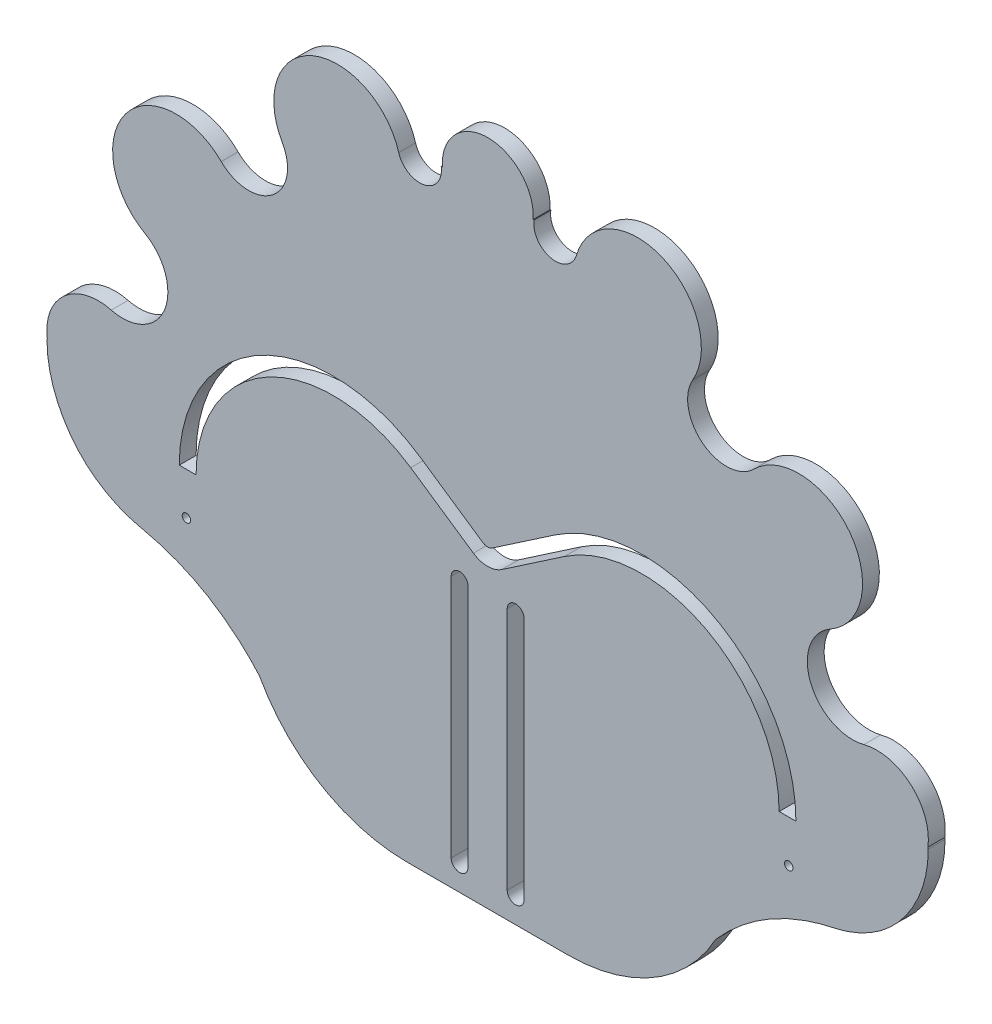
from build123d import *

# Parameters (mm, degrees)
BOSS_EXTRUDE3_DEPTH      = 3
BOSS_EXTRUDE4_DEPTH      = 3
CUT_EXTRUDE11_DEPTH      = 111.873556651
CUT_EXTRUDE11_DEPTH_BACK = 111.873556651
SKETCH6_W                = 30
SKETCH6_H                = 41
BOSS_EXTRUDE5_DEPTH      = 40
SKETCH7_W                = 88.745964224
SKETCH7_H                = 3
BOSS_EXTRUDE6_DEPTH      = 41
CUT_EXTRUDE12_DEPTH      = 118.830155579
CUT_EXTRUDE12_DEPTH_BACK = 118.830155579
BOSS_EXTRUDE7_DEPTH      = 3
CUT_EXTRUDE13_START      = 3
SKETCH11_W               = 10
SKETCH11_H               = 13.79344676
CUT_EXTRUDE13_DEPTH      = 41
SKETCH12_R               = 1.55
CUT_EXTRUDE14_DEPTH      = 118.830155613
CUT_EXTRUDE14_DEPTH_BACK = 118.830155613
SKETCH13_R               = 0.75
CUT_EXTRUDE15_DEPTH      = 118.830155613
CUT_EXTRUDE15_DEPTH_BACK = 118.830155613
CUT_EXTRUDE17_START      = 3
SKETCH14_W               = 30.416262865
SKETCH14_H               = 42.907687787
CUT_EXTRUDE17_DEPTH      = 41
SKETCH16_R               = 1.5
CUT_EXTRUDE19_DEPTH      = 111.873556651
CUT_EXTRUDE19_DEPTH_BACK = 111.873556651


with BuildPart() as part:
    # Sketch2 → Boss-Extrude3 (new body)
    with BuildSketch(Plane.XY):
        with BuildLine():
            ThreePointArc((47.50430531, 50.643316247), (38.392532309, 50.044854207), (36.609276159, 59.000442494))
            ThreePointArc((36.609276159, 59.000442494), (31.22500556, 75.135535905), (15.851175796, 67.857008055))
            ThreePointArc((15.851175796, 67.857008055), (11.292148271, 65.146162721), (8.27578906, 69.509073619))
            ThreePointArc((8.27578906, 69.509073619), (8.209835801, 69.516894322), (8.143875152, 69.524652444))
            ThreePointArc((8.143875152, 69.524652444), (0.040205316, 78.121761213), (-8.072309219, 69.532998094))
            ThreePointArc((-8.072309219, 69.532998094), (-8.174057892, 69.521110302), (-8.27578906, 69.509073619))
            ThreePointArc((-8.27578906, 69.509073619), (-11.292148299, 65.146162715), (-15.851175812, 67.857008111))
            ThreePointArc((-15.851175812, 67.857008111), (-31.225005545, 75.135535912), (-36.609276205, 59.000442573))
            ThreePointArc((-36.609276205, 59.000442573), (-38.39253227, 50.044854237), (-47.504305306, 50.643316242))
            ThreePointArc((-47.504305306, 50.643316242), (-64.562942613, 49.491387864), (-61.124617501, 32.743194941))
            ThreePointArc((-61.124617501, 32.743194941), (-57.616854175, 22.690844698), (-67.122680626, 17.895700022))
            ThreePointArc((-67.122680626, 17.895700022), (-67.381711192, 17.958536274), (-67.642453618, 18.013841027))
            ThreePointArc((-67.642453618, 18.013841027), (-78.427805312, 10.854202298), (-71.372982112, 0))
            Line((-71.372982112, 0), (71.372982112, 0))
            ThreePointArc((71.372982112, 0), (78.369977301, 11.114396723), (67.122680666, 17.895700032))
            ThreePointArc((67.122680666, 17.895700032), (57.616854183, 22.690844679), (61.124617501, 32.743194941))
            ThreePointArc((61.124617501, 32.743194941), (64.562942615, 49.491387862), (47.50430531, 50.643316247))
        make_face()
    extrude(amount=BOSS_EXTRUDE3_DEPTH)

    # Sketch4 → Boss-Extrude4 (add)
    with BuildSketch(Plane.XY):
        with BuildLine():
            Line((-44.372982112, 0), (-57.872982112, 0))
            Line((-57.872982112, 0), (-57.872982112, -13.5))
            ThreePointArc((-57.872982112, -13.5), (-50.941516146, -11.584678656), (-45.97686273, -6.382189564))
            ThreePointArc((-45.97686273, -6.382189564), (-45.287489461, -3.162806043), (-44.372982112, 0))
        make_face()
        with BuildLine():
            Line((-57.872982112, -13.5), (-57.872982112, 0))
            Line((-57.872982112, 0), (-71.372982112, 0))
            ThreePointArc((-71.372982112, 0), (-67.418923658, -9.545941546), (-57.872982112, -13.5))
        make_face()
        with BuildLine():
            Line((-57.872982112, -13.502334306), (-57.872982112, -13.5))
            ThreePointArc((-57.872982112, -13.5), (-67.418923658, -9.545941546), (-71.372982112, 0))
            ThreePointArc((-71.372982112, 0), (-72.451224877, 0.304022071), (-73.484512677, 0.73686523))
            ThreePointArc((-73.484512677, 0.73686523), (-74.477917841, 1.305497745), (-75.393009288, 1.993105481))
            ThreePointArc((-75.393009288, 1.993105481), (-76.19177077, 2.763005392), (-76.892036557, 3.623466668))
            ThreePointArc((-76.892036557, 3.623466668), (-77.482473018, 4.559883509), (-77.956141708, 5.560448192))
            ThreePointArc((-77.956141708, 5.560448192), (-78.314438673, 6.641735343), (-78.536342603, 7.759016536))
            Line((-78.536342603, 7.759016536), (-78.5829279, 7.5))
            add(Edge.make_bspline(
                [(-78.5829279, 7.5), (-78.619378381, 2.110973886), (-75.05397773, -6.403058313), (-65.775580858, -12.380201513), (-60.383408465, -13.5022688), (-57.872982112, -13.502334306)],
                knots=[0, 0, 0, 0, 0.497531388, 0.760341967, 0.99111058, 0.99111058, 0.99111058, 0.99111058], degree=3))
        make_face()
        with BuildLine():
            Line((57.872982112, 0), (44.372982112, 0))
            ThreePointArc((44.372982112, 0), (45.287489461, -3.162806043), (45.97686273, -6.382189564))
            ThreePointArc((45.97686273, -6.382189564), (50.899542414, -11.559461007), (57.775049798, -13.499644783))
            add(Edge.make_bspline(
                [(57.872982112, -13.498764325), (57.840342719, -13.499136412), (57.807698516, -13.49942994), (57.775049798, -13.499644783)],
                knots=[0.991262366, 0.991262366, 0.991262366, 0.991262366, 0.994213276, 0.994213276, 0.994213276, 0.994213276], degree=3))
            Line((57.872982112, -13.498764325), (57.872982112, 0))
        make_face()
        with BuildLine():
            Line((71.372982112, 0), (57.872982112, 0))
            Line((57.872982112, 0), (57.872982112, -13.498764325))
            add(Edge.make_bspline(
                [(58.880524263, -13.462349677), (58.545403195, -13.482744614), (58.209448198, -13.494928627), (57.872982112, -13.498764325)],
                knots=[0.960842647, 0.960842647, 0.960842647, 0.960842647, 0.991262366, 0.991262366, 0.991262366, 0.991262366], degree=3))
            ThreePointArc((58.880524263, -13.462349677), (67.768734207, -9.182814954), (71.372982112, 0))
        make_face()
        with BuildLine():
            ThreePointArc((73.484512677, 0.73686523), (72.451224877, 0.304022071), (71.372982112, 0))
            ThreePointArc((71.372982112, 0), (67.768734207, -9.182814954), (58.880524263, -13.462349677))
            add(Edge.make_bspline(
                [(78.5829279, 7.5), (78.674659632, 1.535679134), (73.703653617, -8.978697254), (63.479979045, -13.182434147), (58.880524263, -13.462349677)],
                knots=[0, 0, 0, 0, 0.543339428, 0.960842647, 0.960842647, 0.960842647, 0.960842647], degree=3))
            Line((78.5829279, 7.5), (78.536342603, 7.759016536))
            ThreePointArc((78.536342603, 7.759016536), (78.314438673, 6.641735343), (77.956141708, 5.560448192))
            ThreePointArc((77.956141708, 5.560448192), (77.482473018, 4.559883509), (76.892036557, 3.623466668))
            ThreePointArc((76.892036557, 3.623466668), (76.19177077, 2.763005392), (75.393009288, 1.993105481))
            ThreePointArc((75.393009288, 1.993105481), (74.477917841, 1.305497745), (73.484512677, 0.73686523))
        make_face()
    extrude(amount=BOSS_EXTRUDE4_DEPTH)

    # Sketch5 → Cut-Extrude11 (cut, two sides)
    with BuildSketch(Plane.XY) as cut_extrude11_sk:
        with BuildLine():
            ThreePointArc((-12.027368937, 22.734284418), (-40.359872584, 24.307893309), (-55, 0))
            Line((-55, 0), (-52, 0))
            ThreePointArc((-52, 0), (-38.956977393, 21.65612313), (-13.715292326, 20.254180663))
            Line((-13.715292326, 20.254180663), (-2.531885083, 12.64291254))
            ThreePointArc((-2.531885083, 12.64291254), (0, 11.863068172), (2.531885083, 12.64291254))
            Line((2.531885083, 12.64291254), (13.715292326, 20.254180663))
            ThreePointArc((13.715292326, 20.254180663), (38.956977393, 21.65612313), (52, 0))
            Line((52, 0), (55, 0))
            ThreePointArc((55, 0), (40.359872584, 24.307893309), (12.027368937, 22.734284418))
            Line((12.027368937, 22.734284418), (0.843961694, 15.123016295))
            ThreePointArc((0.843961694, 15.123016295), (0, 14.863068172), (-0.843961694, 15.123016295))
            Line((-0.843961694, 15.123016295), (-12.027368937, 22.734284418))
        make_face()
    extrude(amount=CUT_EXTRUDE11_DEPTH, mode=Mode.SUBTRACT)
    extrude(cut_extrude11_sk.sketch, amount=-CUT_EXTRUDE11_DEPTH_BACK, mode=Mode.SUBTRACT)

    # Sketch6 → Boss-Extrude5 (add)
    with BuildSketch(Plane.XY):
        with Locations((0, -20.5)):
            Rectangle(SKETCH6_W, SKETCH6_H)
    extrude(amount=BOSS_EXTRUDE5_DEPTH)

    # Sketch7 → Boss-Extrude6 (add)
    with BuildSketch(Plane(origin=(0, 0, 0), x_dir=(1, 0, 0), z_dir=(0, 1, 0))):
        with Locations((0, -1.5)):
            Rectangle(SKETCH7_W, SKETCH7_H)
    extrude(amount=-BOSS_EXTRUDE6_DEPTH)

    # Sketch8 → Cut-Extrude12 (cut, two sides)
    with BuildSketch(Plane.XY) as cut_extrude12_sk:
        with BuildLine():
            Line((44.372982112, -41), (44.372982112, -11))
            ThreePointArc((44.372982112, -11), (35.586185548, -32.213203436), (14.372982112, -41))
            Line((14.372982112, -41), (44.372982112, -41))
        make_face()
        with BuildLine():
            Line((0, -46.518418556), (0, -41))
            Line((0, -41), (-14.372982112, -41))
            ThreePointArc((-14.372982112, -41), (-35.586185548, -32.213203436), (-44.372982112, -11))
            Line((-44.372982112, -11), (-44.372982112, -46.518418556))
            Line((-44.372982112, -46.518418556), (0, -46.518418556))
        make_face()
        Polygon((44.372982112, -46.518418556), (44.372982112, -41), (14.372982112, -41), (0, -41), (0, -46.518418556), align=None)
    extrude(amount=CUT_EXTRUDE12_DEPTH, mode=Mode.SUBTRACT)
    extrude(cut_extrude12_sk.sketch, amount=-CUT_EXTRUDE12_DEPTH_BACK, mode=Mode.SUBTRACT)

    # Sketch10 → Boss-Extrude7 (add)
    with BuildSketch(Plane.XY):
        with BuildLine():
            Line((-62.137396583, -13.014276789), (-43.035731637, 6.087388157))
            Line((-43.035731637, 6.087388157), (-28.63207452, -11.418368831))
            Line((-28.63207452, -11.418368831), (-35.806723464, -31.990348537))
            add(Edge.make_bspline(
                [(-62.137396583, -13.014276789), (-45.493525683, -16.38886663), (-35.806723464, -31.990348537)],
                knots=[0, 0, 0, 1, 1, 1], degree=2))
        make_face()
        with BuildLine():
            Line((43.035731637, 6.087388157), (28.63207452, -11.418368831))
            Line((28.63207452, -11.418368831), (35.806723464, -31.990348537))
            add(Edge.make_bspline(
                [(62.137396583, -13.014276789), (45.493525683, -16.38886663), (35.806723464, -31.990348537)],
                knots=[0, 0, 0, 1, 1, 1], degree=2))
            Line((62.137396583, -13.014276789), (43.035731637, 6.087388157))
        make_face()
    extrude(amount=BOSS_EXTRUDE7_DEPTH)

    # Sketch11 → Cut-Extrude13 (cut)
    with BuildSketch(Plane.XY.offset(CUT_EXTRUDE13_START)):
        with Locations((-10, -20.49672338)):
            Rectangle(SKETCH11_W, SKETCH11_H)
        with Locations((10, -20.49672338)):
            Rectangle(SKETCH11_W, SKETCH11_H)
    extrude(amount=CUT_EXTRUDE13_DEPTH, mode=Mode.SUBTRACT)

    # Sketch12 → Cut-Extrude14 (cut, two sides)
    with BuildSketch(Plane(origin=(0, 0, 0), x_dir=(1, 0, 0), z_dir=(0, 1, 0))) as cut_extrude14_sk:
        with Locations(Location((0, -24, 0), (0, 0, 270))):
            Circle(SKETCH12_R)
    extrude(amount=CUT_EXTRUDE14_DEPTH, mode=Mode.SUBTRACT)
    extrude(cut_extrude14_sk.sketch, amount=-CUT_EXTRUDE14_DEPTH_BACK, mode=Mode.SUBTRACT)

    # Sketch13 → Cut-Extrude15 (cut, two sides)
    with BuildSketch(Plane.XY) as cut_extrude15_sk:
        with Locations((-53.715002972, -7.515993868)):
            Circle(SKETCH13_R)
        with Locations((53.715002972, -7.515993868)):
            Circle(SKETCH13_R)
    extrude(amount=CUT_EXTRUDE15_DEPTH, mode=Mode.SUBTRACT)
    extrude(cut_extrude15_sk.sketch, amount=-CUT_EXTRUDE15_DEPTH_BACK, mode=Mode.SUBTRACT)

    # Sketch14 → Cut-Extrude17 (cut)
    with BuildSketch(Plane.XY.offset(CUT_EXTRUDE17_START)):
        with Locations((0.208131432, -21.453843894)):
            Rectangle(SKETCH14_W, SKETCH14_H)
    extrude(amount=CUT_EXTRUDE17_DEPTH, mode=Mode.SUBTRACT)

    # Sketch16 → Cut-Extrude19 (cut, two sides)
    with BuildSketch(Plane.XY) as cut_extrude19_sk:
        with Locations((-5, 7.085495567)):
            Circle(SKETCH16_R)
        with Locations((5, 7.085495567)):
            Circle(SKETCH16_R)
        with BuildLine():
            ThreePointArc((6.5, 7.085495567), (5, 5.585495567), (3.5, 7.085495567))
            Line((3.5, 7.085495567), (3.5, -34.074581897))
            Line((3.5, -34.074581897), (3.5, -36.414504433))
            ThreePointArc((3.5, -36.414504433), (5, -34.914504433), (6.5, -36.414504433))
            Line((6.5, -36.414504433), (6.5, -34.074581897))
            Line((6.5, -34.074581897), (6.5, 7.085495567))
        make_face()
        with BuildLine():
            ThreePointArc((-3.5, 7.085495567), (-5, 5.585495567), (-6.5, 7.085495567))
            Line((-6.5, 7.085495567), (-6.5, -34.074581897))
            Line((-6.5, -34.074581897), (-6.5, -36.414504433))
            ThreePointArc((-6.5, -36.414504433), (-5, -34.914504433), (-3.5, -36.414504433))
            Line((-3.5, -36.414504433), (-3.5, -34.074581897))
            Line((-3.5, -34.074581897), (-3.5, 7.085495567))
        make_face()
        with Locations((-5, -36.414504433)):
            Circle(SKETCH16_R)
        with Locations((5, -36.414504433)):
            Circle(SKETCH16_R)
    extrude(amount=CUT_EXTRUDE19_DEPTH, mode=Mode.SUBTRACT)
    extrude(cut_extrude19_sk.sketch, amount=-CUT_EXTRUDE19_DEPTH_BACK, mode=Mode.SUBTRACT)


solid = part.part
